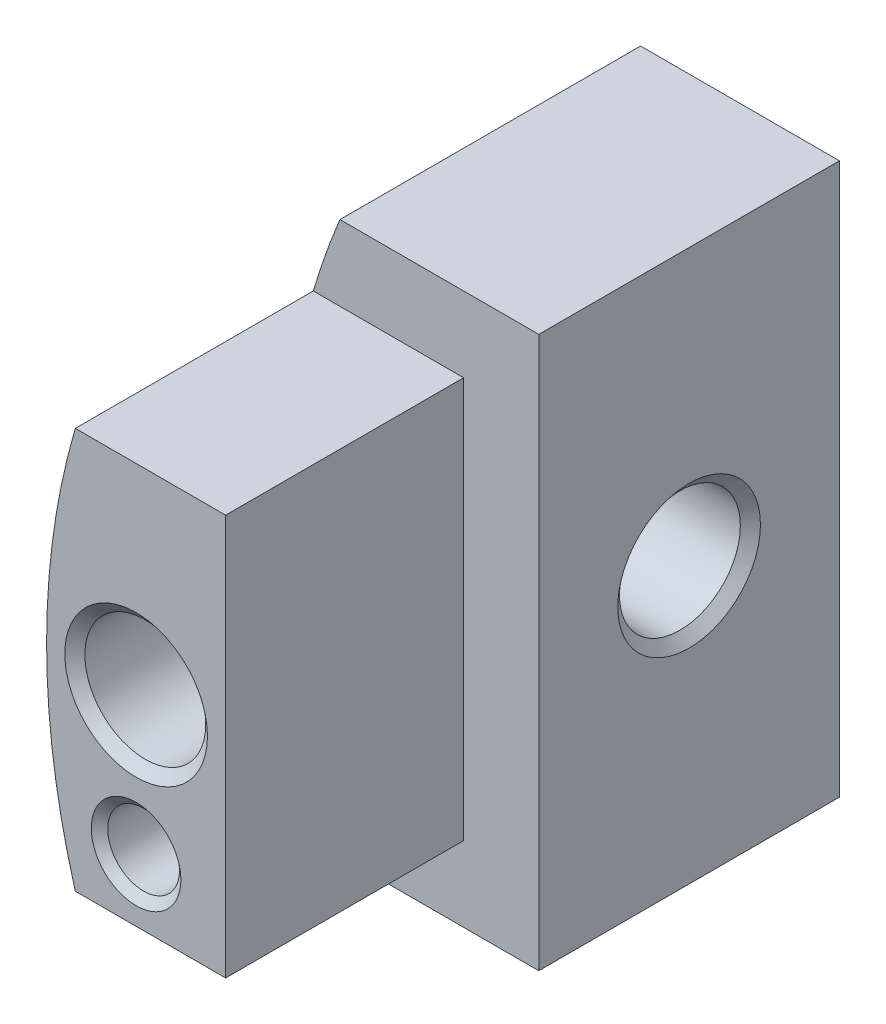
from build123d import *

# Parameters (mm, degrees)
BOSS_EXTRUDE1_DEPTH                    = 30.1625
BOSS_EXTRUDE2_START                    = -38.1
BOSS_EXTRUDE2_DEPTH                    = 38.1
F_3_8_18_NPSM_TAPPED_HOLE1_D           = 15.3162
F_3_8_18_NPSM_TAPPED_HOLE1_DEPTH       = 58.898549293
F_3_8_18_NPSM_TAPPED_HOLE1_CSINK_D     = 18.0848
F_3_8_18_NPSM_TAPPED_HOLE1_CSINK_ANGLE = 100
F_3_8_18_NPSM_TAPPED_HOLE1_TIP         = 4.601450707
F_1_8_27_NPSM_TAPPED_HOLE1_D           = 9.0932
F_1_8_27_NPSM_TAPPED_HOLE1_CSINK_D     = 11.3538
F_1_8_27_NPSM_TAPPED_HOLE1_CSINK_ANGLE = 100
F_3_8_18_NPSM_TAPPED_HOLE2_D           = 15.3162
F_3_8_18_NPSM_TAPPED_HOLE2_DEPTH       = 20.798549293
F_3_8_18_NPSM_TAPPED_HOLE2_CSINK_D     = 18.0848
F_3_8_18_NPSM_TAPPED_HOLE2_CSINK_ANGLE = 100
F_3_8_18_NPSM_TAPPED_HOLE2_TIP         = 4.601450707


with BuildPart() as part:
    # Sketch1 → Boss-Extrude1 (new body)
    with BuildSketch(Plane.XY):
        with BuildLine():
            Line((-67.733292033, 25.4), (-86.783292033, 25.4))
            ThreePointArc((-86.783292033, 25.4), (-90.424, 0), (-86.783292033, -25.4))
            Line((-86.783292033, -25.4), (-67.733292033, -25.4))
            Line((-67.733292033, -25.4), (-67.733292033, 25.4))
        make_face()
    extrude(amount=BOSS_EXTRUDE1_DEPTH)

    # Sketch1_3 → Boss-Extrude2 (add)
    with BuildSketch(Plane.XY.offset(BOSS_EXTRUDE2_START)):
        with BuildLine():
            ThreePointArc((-83.407098924, 34.925), (-90.424, 0), (-83.407098924, -34.925))
            Line((-83.407098924, -34.925), (-58.208292033, -34.925))
            Line((-58.208292033, -34.925), (-58.208292033, 34.925))
            Line((-58.208292033, 34.925), (-83.407098924, 34.925))
        make_face()
    extrude(amount=BOSS_EXTRUDE2_DEPTH)

    # 3_8-18 NPSM Tapped Hole1
    with Locations(Plane(origin=(-79.078646016, 0, 30.1625), x_dir=(1, 0, 0), z_dir=(0, 0, 1))):
        with Locations((0, 0)):
            CounterSinkHole(F_3_8_18_NPSM_TAPPED_HOLE1_D / 2, F_3_8_18_NPSM_TAPPED_HOLE1_CSINK_D / 2, depth=F_3_8_18_NPSM_TAPPED_HOLE1_DEPTH, counter_sink_angle=F_3_8_18_NPSM_TAPPED_HOLE1_CSINK_ANGLE)
            with Locations((0, 0, -(F_3_8_18_NPSM_TAPPED_HOLE1_DEPTH + F_3_8_18_NPSM_TAPPED_HOLE1_TIP / 2))):  # 118° drill point
                Cone(0, F_3_8_18_NPSM_TAPPED_HOLE1_D / 2, F_3_8_18_NPSM_TAPPED_HOLE1_TIP, mode=Mode.SUBTRACT)

    # 1_8-27 NPSM Tapped Hole1 (through all)
    with Locations(Plane(origin=(-79.078646016, -17.4625, 30.1625), x_dir=(1, 0, 0), z_dir=(0, 0, 1))):
        with Locations((0, 0)):
            CounterSinkHole(F_1_8_27_NPSM_TAPPED_HOLE1_D / 2, F_1_8_27_NPSM_TAPPED_HOLE1_CSINK_D / 2, counter_sink_angle=F_1_8_27_NPSM_TAPPED_HOLE1_CSINK_ANGLE)

    # 3_8-18 NPSM Tapped Hole2
    with Locations(Plane(origin=(-58.208292033, 0, 0), x_dir=(0, 0, -1), z_dir=(1, 0, 0))):
        with Locations((19.05, 0)):
            CounterSinkHole(F_3_8_18_NPSM_TAPPED_HOLE2_D / 2, F_3_8_18_NPSM_TAPPED_HOLE2_CSINK_D / 2, depth=F_3_8_18_NPSM_TAPPED_HOLE2_DEPTH, counter_sink_angle=F_3_8_18_NPSM_TAPPED_HOLE2_CSINK_ANGLE)
            with Locations((0, 0, -(F_3_8_18_NPSM_TAPPED_HOLE2_DEPTH + F_3_8_18_NPSM_TAPPED_HOLE2_TIP / 2))):  # 118° drill point
                Cone(0, F_3_8_18_NPSM_TAPPED_HOLE2_D / 2, F_3_8_18_NPSM_TAPPED_HOLE2_TIP, mode=Mode.SUBTRACT)


solid = part.part
